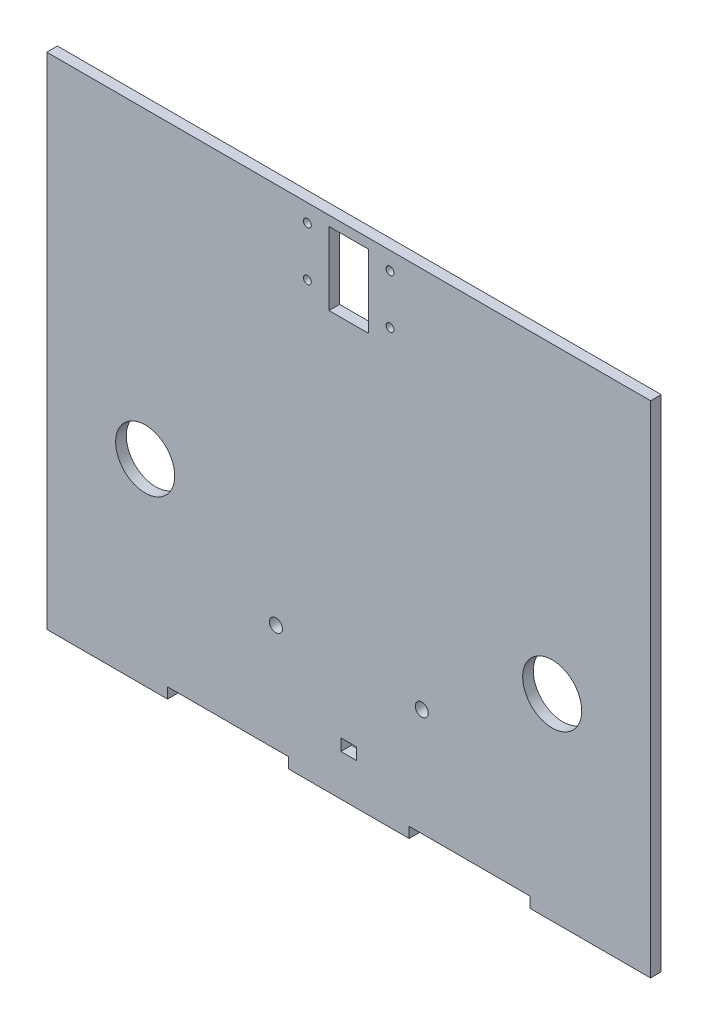
from build123d import *

# Parameters (mm, degrees)
SKETCH1_R           = 1.65
SKETCH1_R_2         = 7.5
SKETCH1_R_3         = 1
SKETCH1_W           = 4
SKETCH1_H           = 3
SKETCH1_W_2         = 10
SKETCH1_H_2         = 18.5
BOSS_EXTRUDE3_DEPTH = 2.7


with BuildPart() as part:
    # Sketch1 → Boss-Extrude3 (new body)
    with BuildSketch(Plane.XY):
        Polygon((-46.02, -28), (-46.02, -25.3), (-15.34, -25.3), (-15.34, -28), (15.34, -28), (15.34, -25.3), (46.02, -25.3), (46.02, -28), (76.7, -28), (76.7, 99), (-76.7, 99), (-76.7, -28), align=None)
        with Locations((-18.5, 2)):
            Circle(SKETCH1_R, mode=Mode.SUBTRACT)
        with Locations((18.567940233, 2)):
            Circle(SKETCH1_R, mode=Mode.SUBTRACT)
        with Locations((-51.7, 22)):
            Circle(SKETCH1_R_2, mode=Mode.SUBTRACT)
        with Locations((51.7, 22)):
            Circle(SKETCH1_R_2, mode=Mode.SUBTRACT)
        with Locations((10.5, 94.5)):
            Circle(SKETCH1_R_3, mode=Mode.SUBTRACT)
        with Locations((-10.5, 82)):
            Circle(SKETCH1_R_3, mode=Mode.SUBTRACT)
        with Locations((-10.5, 94.5)):
            Circle(SKETCH1_R_3, mode=Mode.SUBTRACT)
        with Locations((10.5, 82)):
            Circle(SKETCH1_R_3, mode=Mode.SUBTRACT)
        with Locations((0, -16)):
            Rectangle(SKETCH1_W, SKETCH1_H, mode=Mode.SUBTRACT)
        with Locations((0, 87.25)):
            Rectangle(SKETCH1_W_2, SKETCH1_H_2, mode=Mode.SUBTRACT)
    extrude(amount=BOSS_EXTRUDE3_DEPTH)


solid = part.part
